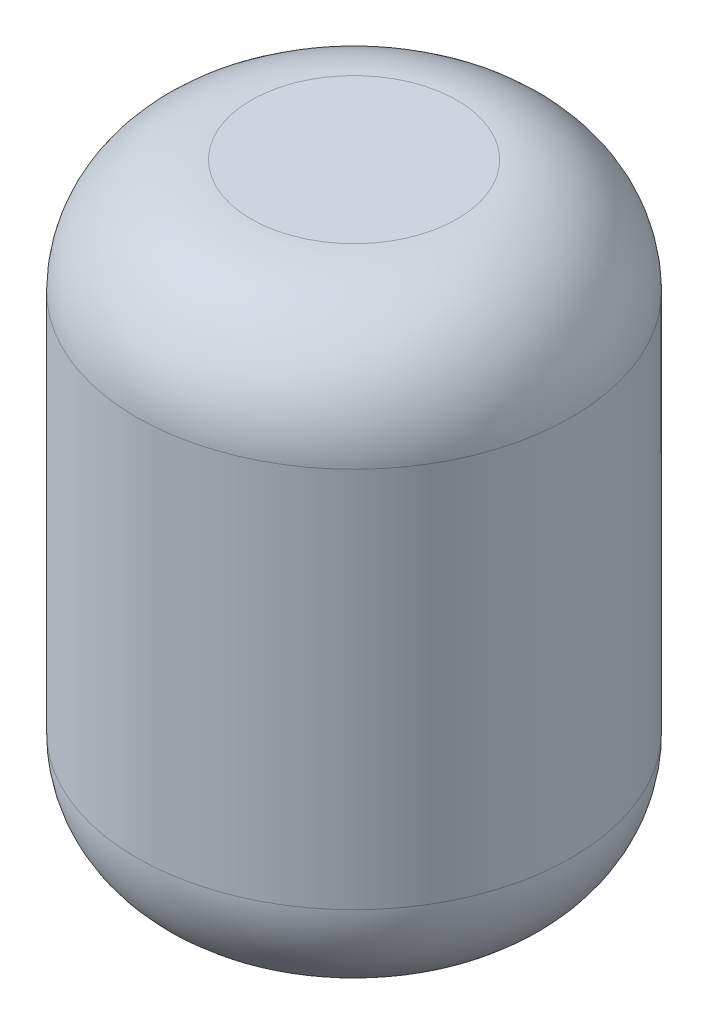
from build123d import *

# Parameters (mm, degrees)
SKETCH1_R           = 72.388504202
BOSS_EXTRUDE1_DEPTH = 203.2
FILLET1_R           = 38.1


with BuildPart() as part:
    # Sketch1 → Boss-Extrude1 (new body)
    with BuildSketch(Plane(origin=(0, 0, 0), x_dir=(1, 0, 0), z_dir=(0, 1, 0))):
        Circle(SKETCH1_R)
    extrude(amount=BOSS_EXTRUDE1_DEPTH)

    # Fillet1
    fillet1_edges = [part.edges().sort_by_distance(p)[0] for p in [
        (-72.388504202, 0, 0),
        (-72.388504202, 203.2, 0),
    ]]
    fillet(fillet1_edges, radius=FILLET1_R)


solid = part.part
